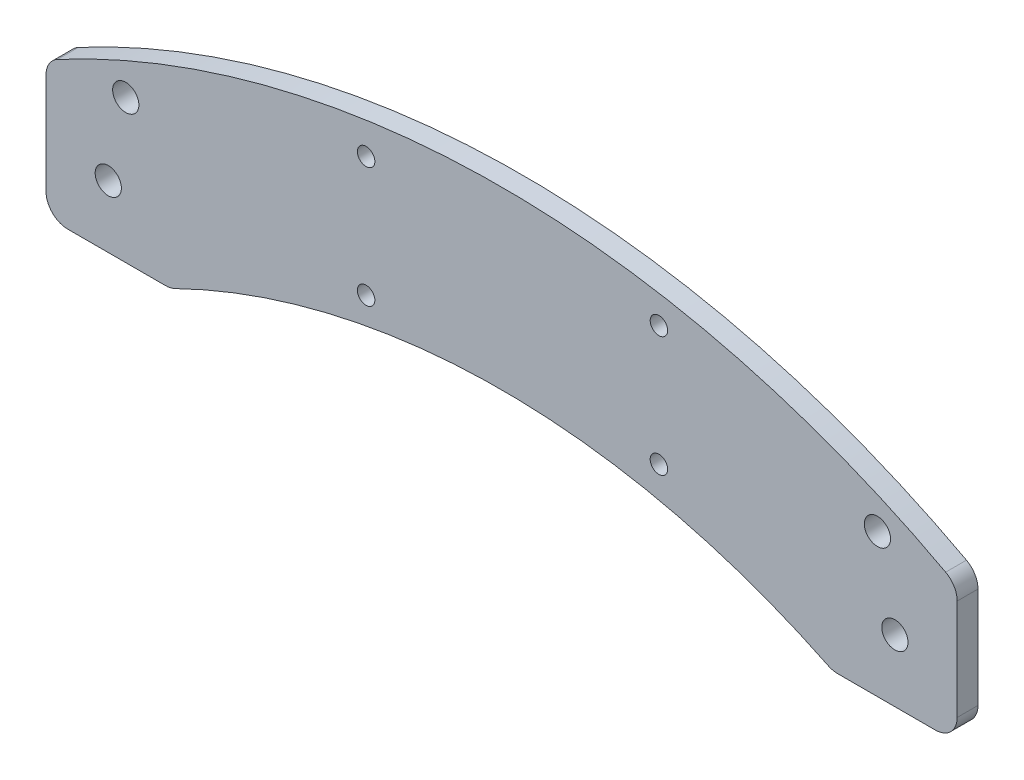
from build123d import *

# Parameters (mm, degrees)
SKETCH1_R           = 2
SKETCH1_R_2         = 3
BOSS_EXTRUDE1_DEPTH = 4.7625


with BuildPart() as part:
    # Sketch1 → Boss-Extrude1 (new body)
    with BuildSketch(Plane.XY):
        with BuildLine():
            Line((-14.25, -9.25), (-14.25, 13.816035512))
            ThreePointArc((-14.25, 13.816035512), (-13.540423999, 16.383575561), (-11.613095238, 18.222369691))
            ThreePointArc((-11.613095238, 18.222369691), (90, 43.75), (191.613095238, 18.222369691))
            ThreePointArc((191.613095238, 18.222369691), (193.540423999, 16.383575561), (194.25, 13.816035512))
            Line((194.25, 13.816035512), (194.25, -9.25))
            ThreePointArc((194.25, -9.25), (192.785533906, -12.785533906), (189.25, -14.25))
            Line((189.25, -14.25), (166.91656424, -14.25))
            ThreePointArc((166.91656424, -14.25), (165.788685845, -14.121128239), (164.718948119, -13.74115613))
            ThreePointArc((164.718948119, -13.74115613), (90, 3.55953545), (15.281051881, -13.74115613))
            ThreePointArc((15.281051881, -13.74115613), (14.211314155, -14.121128239), (13.08343576, -14.25))
            Line((13.08343576, -14.25), (-9.25, -14.25))
            ThreePointArc((-9.25, -14.25), (-12.785533906, -12.785533906), (-14.25, -9.25))
        make_face()
        with Locations((59, 34.290496826)):
            Circle(SKETCH1_R, mode=Mode.SUBTRACT)
        with Locations((59, 6.790496826)):
            Circle(SKETCH1_R, mode=Mode.SUBTRACT)
        with Locations((126, 34.290496826)):
            Circle(SKETCH1_R, mode=Mode.SUBTRACT)
        with Locations((126, 6.790496826)):
            Circle(SKETCH1_R, mode=Mode.SUBTRACT)
        with Locations((180, 0)):
            Circle(SKETCH1_R_2, mode=Mode.SUBTRACT)
        Circle(SKETCH1_R_2, mode=Mode.SUBTRACT)
        with Locations((4, 18.5)):
            Circle(SKETCH1_R_2, mode=Mode.SUBTRACT)
        with Locations((176, 18.5)):
            Circle(SKETCH1_R_2, mode=Mode.SUBTRACT)
    extrude(amount=BOSS_EXTRUDE1_DEPTH)


solid = part.part
